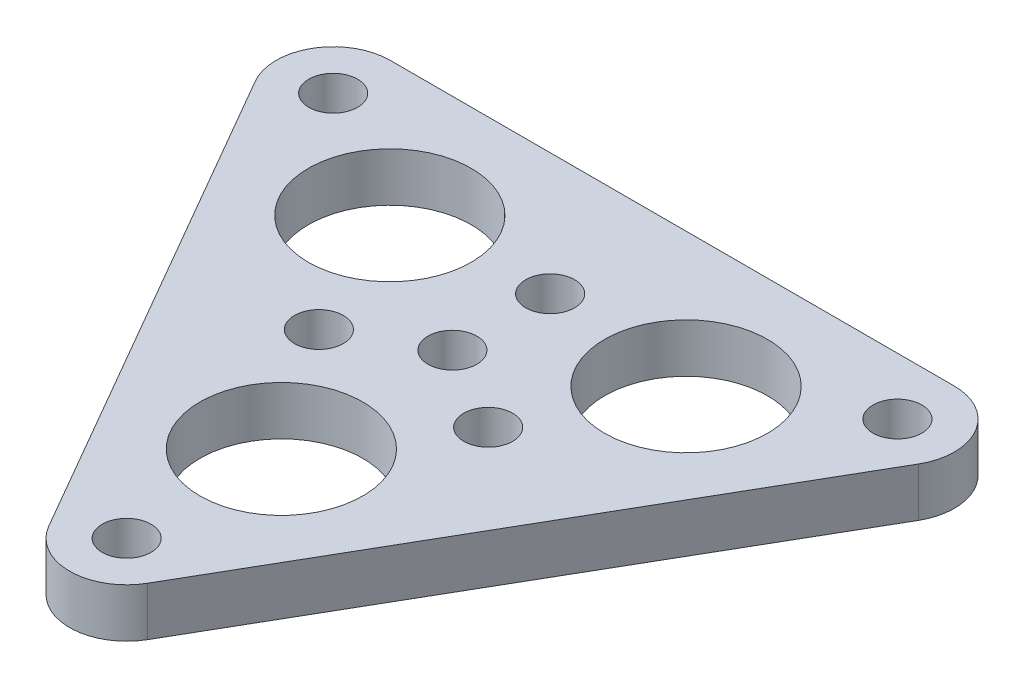
from build123d import *

# Parameters (mm, degrees)
SKETCH_1_R      = 1.5
SKETCH_1_R_2    = 5
EXTRUDE_1_DEPTH = 3


with BuildPart() as part:
    # 草图1 → 凸台-拉伸1 (new body)
    with BuildSketch(Plane(origin=(0, 0, 0), x_dir=(-1, 0, 0), z_dir=(0, 1, 0))):
        with BuildLine():
            Line((-3.031088913, 21.75), (-20.351596989, -8.25))
            ThreePointArc((-20.351596989, -8.25), (-20.351596989, -11.75), (-17.320508076, -13.5))
            Line((-17.320508076, -13.5), (17.320508076, -13.5))
            ThreePointArc((17.320508076, -13.5), (20.351596989, -11.75), (20.351596989, -8.25))
            Line((20.351596989, -8.25), (3.031088913, 21.75))
            ThreePointArc((3.031088913, 21.75), (0, 23.5), (-3.031088913, 21.75))
        make_face()
        with Locations((0, 20)):
            Circle(SKETCH_1_R, mode=Mode.SUBTRACT)
        with Locations((17.320508076, -10)):
            Circle(SKETCH_1_R, mode=Mode.SUBTRACT)
        with Locations((-17.320508076, -10)):
            Circle(SKETCH_1_R, mode=Mode.SUBTRACT)
        with Locations((-5.196152423, 3)):
            Circle(SKETCH_1_R, mode=Mode.SUBTRACT)
        Circle(SKETCH_1_R, mode=Mode.SUBTRACT)
        with Locations((0, 10.5)):
            Circle(SKETCH_1_R_2, mode=Mode.SUBTRACT)
        with Locations((9.09326674, -5.25)):
            Circle(SKETCH_1_R_2, mode=Mode.SUBTRACT)
        with Locations((-9.09326674, -5.25)):
            Circle(SKETCH_1_R_2, mode=Mode.SUBTRACT)
        with Locations((0, -6)):
            Circle(SKETCH_1_R, mode=Mode.SUBTRACT)
        with Locations((5.196152423, 3)):
            Circle(SKETCH_1_R, mode=Mode.SUBTRACT)
    extrude(amount=EXTRUDE_1_DEPTH)


solid = part.part
